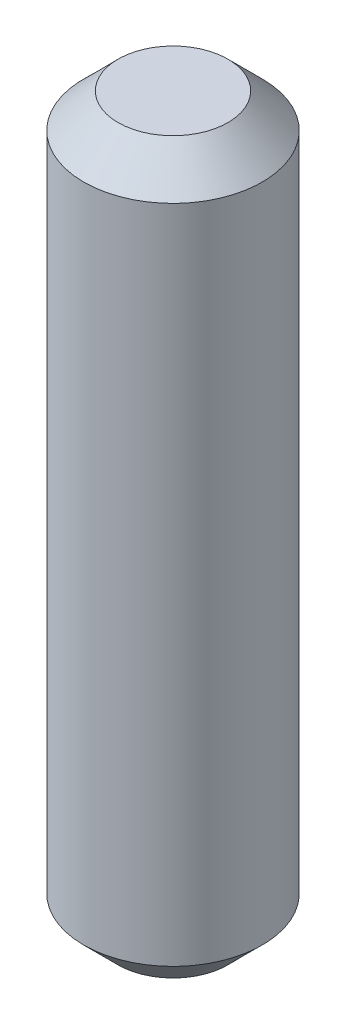
from build123d import *

# Parameters (mm, degrees)
SKETCH2_R           = 1.651
BOSS_EXTRUDE1_DEPTH = 13.4874
CHAMFER1_SIZE       = 0.635


with BuildPart() as part:
    # Sketch2 → Boss-Extrude1 (new body)
    with BuildSketch(Plane(origin=(0, 0, 0), x_dir=(1, 0, 0), z_dir=(0, 1, 0))):
        Circle(SKETCH2_R)
    extrude(amount=BOSS_EXTRUDE1_DEPTH)

    # Chamfer1
    chamfer1_edges = [part.edges().sort_by_distance(p)[0] for p in [
        (-1.651, 0, 0),
        (-1.651, 13.4874, 0),
    ]]
    chamfer(chamfer1_edges, length=CHAMFER1_SIZE)


solid = part.part
